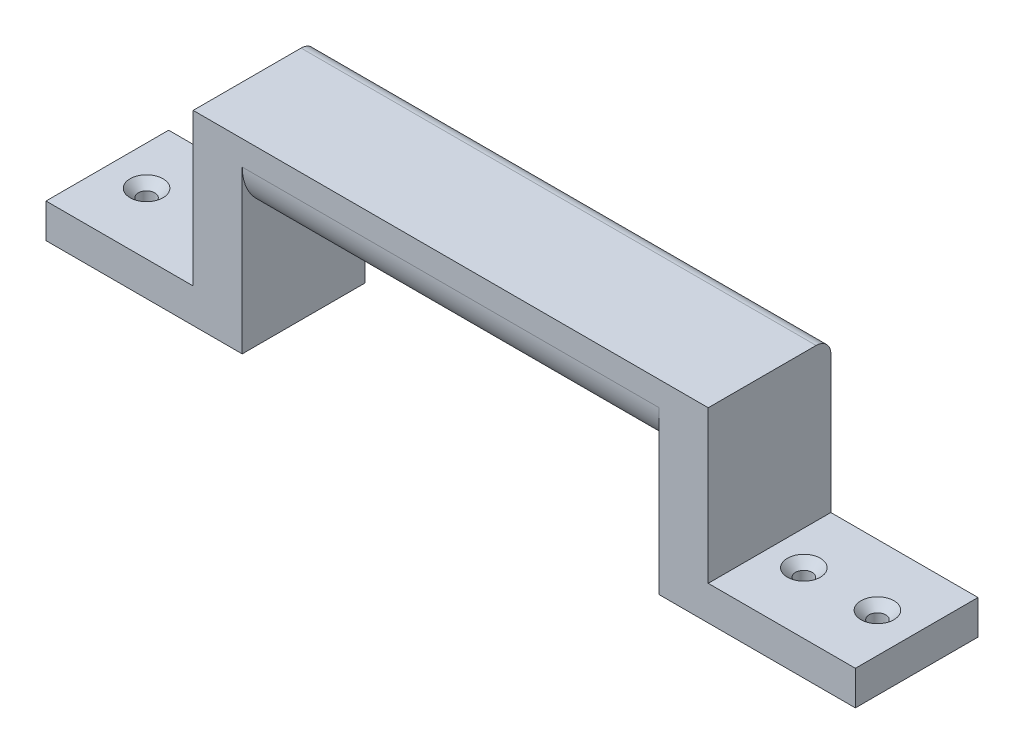
from build123d import *

# Parameters (mm, degrees)
SALIENTE_EXTRUIR1_DEPTH                              = 25
REDONDEO1_R                                          = 10
REDONDEO2_R                                          = 3
CROQUIS2_R                                           = 1.5
CORTAR_EXTRUIR1_DEPTH                                = 9
REFRENTADO_PARA_TORNILLO_TAP_N_CON_CABEZ_D           = 3.4
REFRENTADO_PARA_TORNILLO_TAP_N_CON_CABEZ_CSINK_D     = 6.72
REFRENTADO_PARA_TORNILLO_TAP_N_CON_CABEZ_CSINK_ANGLE = 90
CROQUIS5_W                                           = 40
CROQUIS5_H                                           = 2
CORTAR_EXTRUIR2_DEPTH                                = 25


with BuildPart() as part:
    # Croquis1 → Saliente-Extruir1 (new body)
    with BuildSketch(Plane.XY):
        Polygon((-96.521895292, -23.642699491), (-136.521895292, -23.642699491), (-136.521895292, -14.642699491), (-106.521895292, -14.642699491), (-106.521895292, 16.357300509), (-1.521895292, 16.357300509), (-1.521895292, -14.642699491), (28.478104708, -14.642699491), (28.478104708, -23.642699491), (-11.521895292, -23.642699491), (-11.521895292, 1.357300509), (-96.521895292, 1.357300509), align=None)
    extrude(amount=SALIENTE_EXTRUIR1_DEPTH)

    # Redondeo1
    redondeo1_edges = [part.edges().sort_by_distance(p)[0] for p in [
        (-54.021895292, 1.357300509, 0),
        (-54.021895292, 1.357300509, 25),
    ]]
    fillet(redondeo1_edges, radius=REDONDEO1_R)

    # Redondeo2
    redondeo2_edges = [part.edges().sort_by_distance(p)[0] for p in [
        (-54.021895292, 16.357300509, 0),
    ]]
    fillet(redondeo2_edges, radius=REDONDEO2_R)

    # Croquis2 → Cortar-Extruir1 (cut)
    with BuildSketch(Plane(origin=(0, -14.642699491, 0), x_dir=(1, 0, 0), z_dir=(0, 1, 0))):
        with Locations((-113.521895292, -12.5)):
            Circle(CROQUIS2_R)
        with Locations((-128.521895292, -12.5)):
            Circle(CROQUIS2_R)
        with Locations((20.478104708, -12.5)):
            Circle(CROQUIS2_R)
        with Locations((5.478104708, -12.5)):
            Circle(CROQUIS2_R)
    extrude(amount=-CORTAR_EXTRUIR1_DEPTH, mode=Mode.SUBTRACT)

    # Refrentado para tornillo tapón con cabeza plana de clavija de M31 (through all)
    with Locations(Plane(origin=(0, -14.642699491, 0), x_dir=(1, 0, 0), z_dir=(0, 1, 0))):
        with Locations((-128.521895292, -12.5), (-113.521895292, -12.5), (20.478104708, -12.5), (5.478104708, -12.5)):
            CounterSinkHole(REFRENTADO_PARA_TORNILLO_TAP_N_CON_CABEZ_D / 2, REFRENTADO_PARA_TORNILLO_TAP_N_CON_CABEZ_CSINK_D / 2, counter_sink_angle=REFRENTADO_PARA_TORNILLO_TAP_N_CON_CABEZ_CSINK_ANGLE)

    # Croquis5 → Cortar-Extruir2 (cut)
    with BuildSketch(Plane.XY.offset(25)):
        with Locations((-116.521895292, -22.642699491)):
            Rectangle(CROQUIS5_W, CROQUIS5_H)
        with Locations((8.478104708, -22.642699491)):
            Rectangle(CROQUIS5_W, CROQUIS5_H)
    extrude(amount=-CORTAR_EXTRUIR2_DEPTH, mode=Mode.SUBTRACT)


solid = part.part
